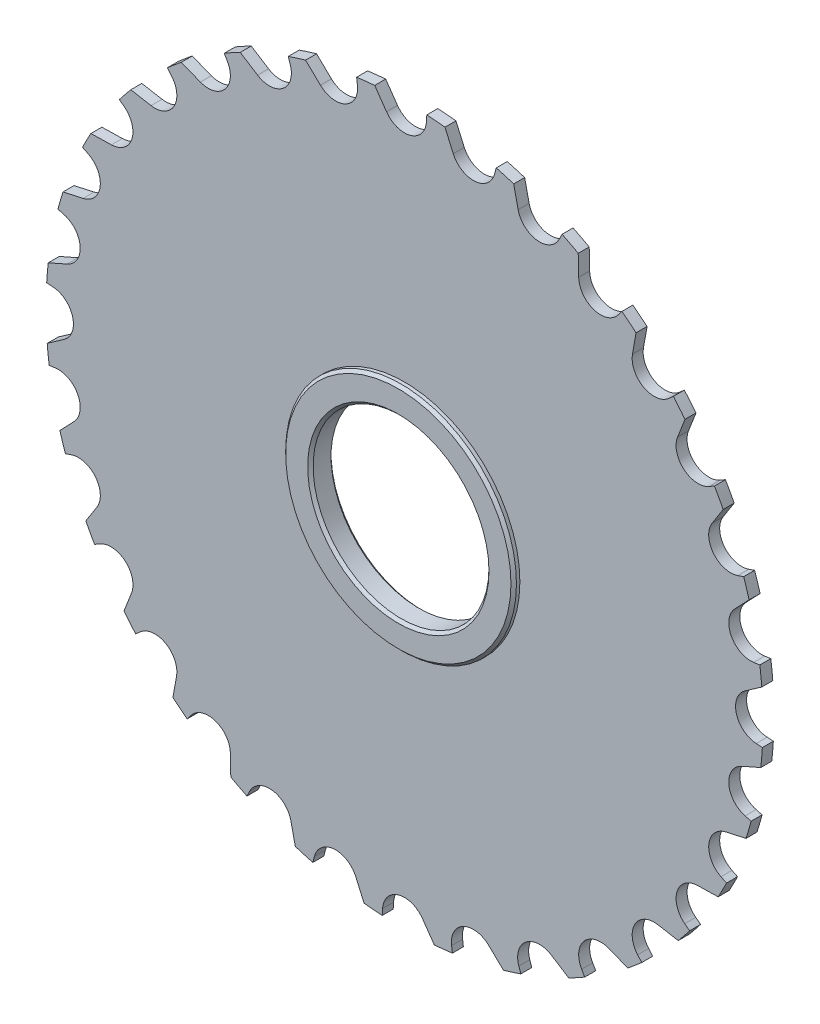
from build123d import *

# Parameters (mm, degrees)
ESQUISSE1_R                  = 65.25
EXTRUSION1_DEPTH             = 1
ENL_V_MAT_EXTRU_1_DEPTH      = 2
R_P_TITION_CIRCULAIRE1_COUNT = 32
ESQUISSE3_R                  = 21
EXTRUSION2_DEPTH             = 2.125
ESQUISSE4_R                  = 16
ENL_V_MAT_EXTRU_2_DEPTH      = 3.125
ENL_V_MAT_EXTRU_2_DEPTH_BACK = 3.125
CHANFREIN1_SIZE              = 0.5


with BuildPart() as part:
    # Esquisse1 → Extrusion1 (new body, symmetric)
    with BuildSketch(Plane.XY):
        Circle(ESQUISSE1_R)
    extrude(amount=EXTRUSION1_DEPTH, both=True)

    # Esquisse2 → Enlèv. mat.-Extru.1 (cut, symmetric)
    with BuildSketch(Plane.XY):
        with BuildLine():
            Line((-5.425113212, 65.024077438), (-3.276608177, 61.955694255))
            ThreePointArc((-3.276608177, 61.955694255), (1.083431356, 60.399522563), (3.992240653, 64.000972763))
            Line((3.992240653, 64.000972763), (4.062256809, 65.123425659))
            ThreePointArc((4.062256809, 65.123425659), (-0.683236351, 65.246422799), (-5.425113212, 65.024077438))
        make_face()
    enl_v_mat_extru_1 = extrude(amount=ENL_V_MAT_EXTRU_1_DEPTH, both=True, mode=Mode.SUBTRACT)

    # Répétition circulaire1: Enlèv. mat.-Extru.1 ×32 about axis
    r_p_tition_circulaire1_axis = Axis((0, 0, 0), (0, 0, 1))
    for i in range(1, R_P_TITION_CIRCULAIRE1_COUNT):
        add(enl_v_mat_extru_1.rotate(r_p_tition_circulaire1_axis, i * 360 / R_P_TITION_CIRCULAIRE1_COUNT), mode=Mode.SUBTRACT)

    # Esquisse3 → Extrusion2 (add, symmetric)
    with BuildSketch(Plane.XY):
        Circle(ESQUISSE3_R)
    extrude(amount=EXTRUSION2_DEPTH, both=True)

    # Esquisse4 → Enlèv. mat.-Extru.2 (cut, two sides)
    with BuildSketch(Plane.XY) as enl_v_mat_extru_2_sk:
        Circle(ESQUISSE4_R)
    extrude(amount=ENL_V_MAT_EXTRU_2_DEPTH, mode=Mode.SUBTRACT)
    extrude(enl_v_mat_extru_2_sk.sketch, amount=-ENL_V_MAT_EXTRU_2_DEPTH_BACK, mode=Mode.SUBTRACT)

    # Chanfrein1
    chanfrein1_edges = [part.edges().sort_by_distance(p)[0] for p in [
        (-21, 0, -2.125),
        (-21, 0, 2.125),
        (-16, 0, -2.125),
        (-16, 0, 2.125),
    ]]
    chamfer(chanfrein1_edges, length=CHANFREIN1_SIZE)


solid = part.part
